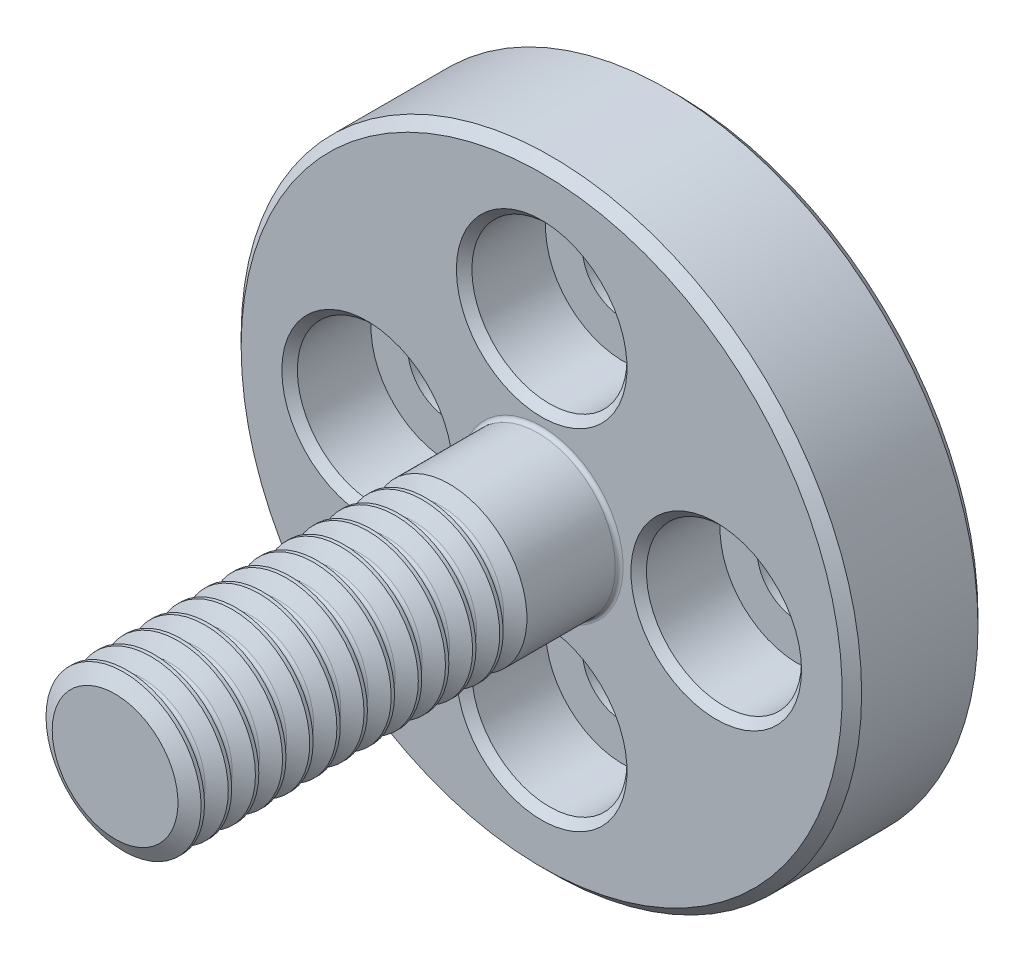
from build123d import *

# Parameters (mm, degrees)
CHAMBRAGE_POUR_VIS_T_TE_HEXAGONALE_M21_D           = 2.1
CHAMBRAGE_POUR_VIS_T_TE_HEXAGONALE_M21_CBORE_D     = 4
CHAMBRAGE_POUR_VIS_T_TE_HEXAGONALE_M21_CBORE_DEPTH = 2.1
R_P_TITION_CIRCULAIRE1_COUNT                       = 4
ESQUISSE4_R                                        = 1
ENL_V_MAT_EXTRU_1_DEPTH                            = 3.5
R_P_TITION_LIN_AIRE1_COUNT                         = 13
R_P_TITION_LIN_AIRE1_PITCH                         = 0.7
CHANFREIN1_SIZE                                    = 0.2
CHANFREIN2_SIZE                                    = 0.25
CONG_2_R                                           = 0.1


with BuildPart() as part:
    # Esquisse1 → Révolution1 (revolve)
    with BuildSketch(Plane(origin=(0, 0, 0), x_dir=(0, 0, -1), z_dir=(1, 0, 0)), mode=Mode.PRIVATE) as r_volution1_sk:
        Polygon((0, 0), (0, 8), (-3.5, 8), (-3.5, 2), (-14.5, 2), (-14.5, 0), align=None)
    revolve(r_volution1_sk.sketch.rotate(Axis((0, 0, 1000), (0, 0, -1)), 90), axis=Axis((0, 0, 1000), (0, 0, -1)))

    # Chambrage pour vis à tête hexagonale M21 (through all)
    with Locations(Plane.XY.offset(3.5)):
        with Locations((0, 4.5)):
            chambrage_pour_vis_t_te_hexagonale_m21 = CounterBoreHole(CHAMBRAGE_POUR_VIS_T_TE_HEXAGONALE_M21_D / 2, CHAMBRAGE_POUR_VIS_T_TE_HEXAGONALE_M21_CBORE_D / 2, CHAMBRAGE_POUR_VIS_T_TE_HEXAGONALE_M21_CBORE_DEPTH)

    # Répétition circulaire1: Chambrage pour vis à tête hexagonale M21 ×4 about axis
    r_p_tition_circulaire1_axis = Axis((0, 0, 0), (0, 0, 1))
    for i in range(1, R_P_TITION_CIRCULAIRE1_COUNT):
        add(chambrage_pour_vis_t_te_hexagonale_m21.rotate(r_p_tition_circulaire1_axis, i * 360 / R_P_TITION_CIRCULAIRE1_COUNT), mode=Mode.SUBTRACT)

    # Esquisse4 → Enlèv. mat.-Extru.1 (cut)
    with BuildSketch(Plane(origin=(0, 0, 0), x_dir=(-1, 0, 0), z_dir=(0, 0, -1))):
        Circle(ESQUISSE4_R)
    extrude(amount=-ENL_V_MAT_EXTRU_1_DEPTH, mode=Mode.SUBTRACT)

    # Esquisse13 → Enlèvement de matière-Révolution1 (revolve, cut)
    with BuildSketch(Plane(origin=(0, 0, 0), x_dir=(0, 0, -1), z_dir=(1, 0, 0)), mode=Mode.PRIVATE) as enl_vement_de_mati_re_r_volution1_sk:
        Polygon((-14.5875, 1.621125), (-14.5875, 2.075775), (-14.9375, 2.075775), (-14.675, 1.621125), align=None)
        Polygon((-14.5, 1.621125), (-14.2375, 2.075775), (-14.5875, 2.075775), (-14.5875, 1.621125), align=None)
        with BuildLine():
            ThreePointArc((-14.5875, 1.570607592), (-14.536982037, 1.584143668), (-14.5, 1.621125))
            Line((-14.5, 1.621125), (-14.5875, 1.621125))
            Line((-14.5875, 1.621125), (-14.5875, 1.570607592))
        make_face()
        with BuildLine():
            Line((-14.5875, 1.570607592), (-14.5875, 1.621125))
            Line((-14.5875, 1.621125), (-14.675, 1.621125))
            ThreePointArc((-14.675, 1.621125), (-14.638017963, 1.584143668), (-14.5875, 1.570607592))
        make_face()
    enl_vement_de_mati_re_r_volution1 = revolve(enl_vement_de_mati_re_r_volution1_sk.sketch.rotate(Axis((0, 0, 1000), (0, 0, 1)), 270), axis=Axis((0, 0, 1000), (0, 0, 1)), mode=Mode.SUBTRACT)

    # Répétition linéaire1: Enlèvement de matière-Révolution1 ×13
    with Locations(*[(0, 0, -i * R_P_TITION_LIN_AIRE1_PITCH) for i in range(1, R_P_TITION_LIN_AIRE1_COUNT)]):
        add(enl_vement_de_mati_re_r_volution1, mode=Mode.SUBTRACT)

    # Chanfrein1
    chanfrein1_edges = [part.edges().sort_by_distance(p)[0] for p in [
        (-2, 4.5, 3.5),
        (-4.5, -2, 3.5),
        (2, -4.5, 3.5),
        (4.5, 2, 3.5),
    ]]
    chamfer(chanfrein1_edges, length=CHANFREIN1_SIZE)

    # Chanfrein2
    chanfrein2_edges = [part.edges().sort_by_distance(p)[0] for p in [
        (-8, 0, 3.5),
        (-8, 0, 0),
    ]]
    chamfer(chanfrein2_edges, length=CHANFREIN2_SIZE)

    # Congé2
    cong_2_edges = [part.edges().sort_by_distance(p)[0] for p in [
        (-2, 0, 3.5),
    ]]
    fillet(cong_2_edges, radius=CONG_2_R)


solid = part.part
